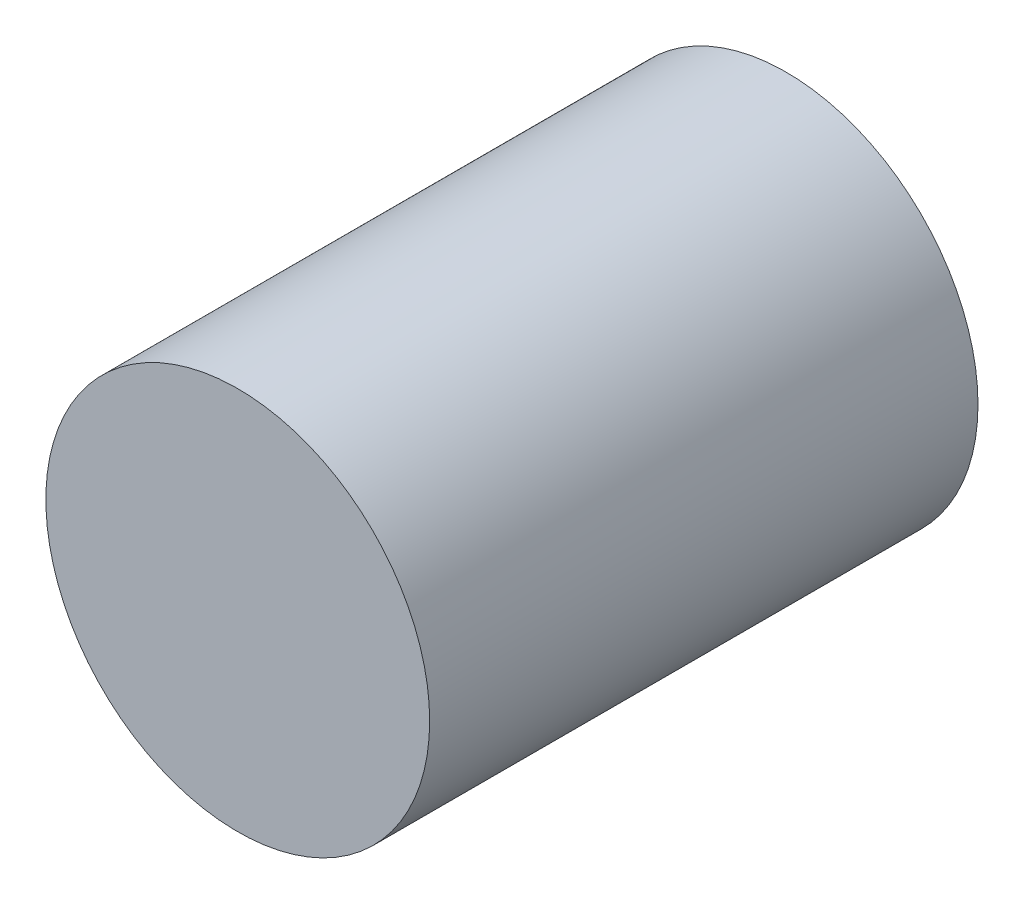
from build123d import *

# Parameters (mm, degrees)
SKETCH1_R           = 1.75
BOSS_EXTRUDE1_DEPTH = 5


with BuildPart() as part:
    # Sketch1 → Boss-Extrude1 (new body)
    with BuildSketch(Plane.XY):
        Circle(SKETCH1_R)
    extrude(amount=BOSS_EXTRUDE1_DEPTH)


solid = part.part
